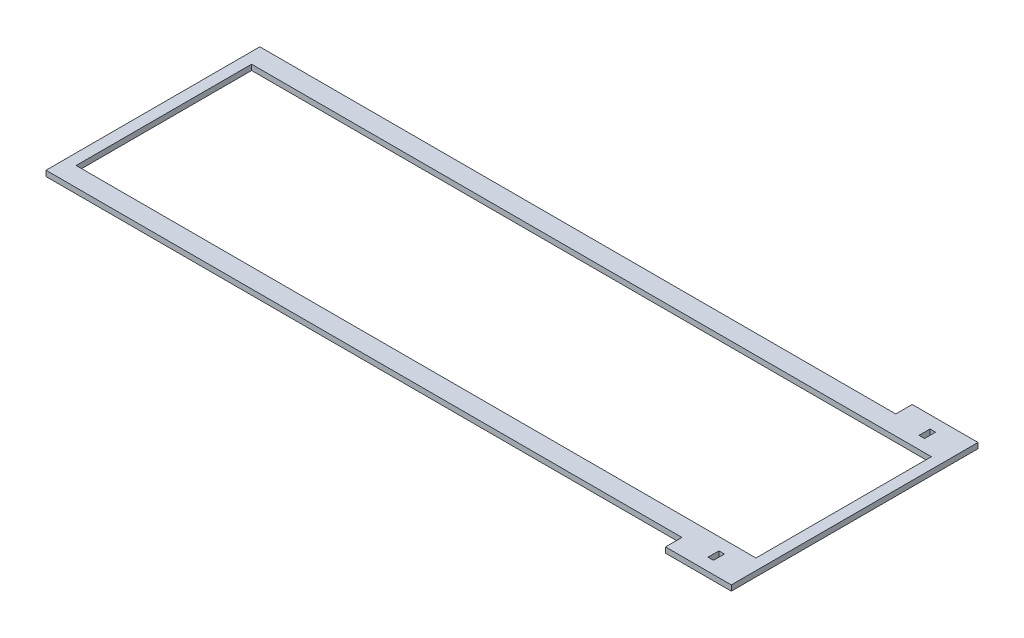
from build123d import *

# Parameters (mm, degrees)
SKETCH1_W           = 3.175
SKETCH1_H           = 6.35
SKETCH1_W_2         = 393.7
SKETCH1_H_2         = 101.6
BOSS_EXTRUDE1_DEPTH = 1.5875


with BuildPart() as part:
    # Sketch1 → Boss-Extrude1 (new body, symmetric)
    with BuildSketch(Plane(origin=(0, 0, 0), x_dir=(1, 0, 0), z_dir=(0, 1, 0))):
        Polygon((203.2, 71.4375), (165.1, 71.4375), (165.1, 61.9125), (-203.2, 61.9125), (-203.2, 50.8), (-203.2, -50.8), (-203.2, -61.9125), (165.1, -61.9125), (165.1, -71.4375), (203.2, -71.4375), (203.2, -50.8), (203.2, 50.8), align=None)
        with Locations((184.15, -61.11875)):
            Rectangle(SKETCH1_W, SKETCH1_H, mode=Mode.SUBTRACT)
        Rectangle(SKETCH1_W_2, SKETCH1_H_2, mode=Mode.SUBTRACT)
        with Locations((184.15, 61.11875)):
            Rectangle(SKETCH1_W, SKETCH1_H, mode=Mode.SUBTRACT)
    extrude(amount=BOSS_EXTRUDE1_DEPTH, both=True)


solid = part.part
